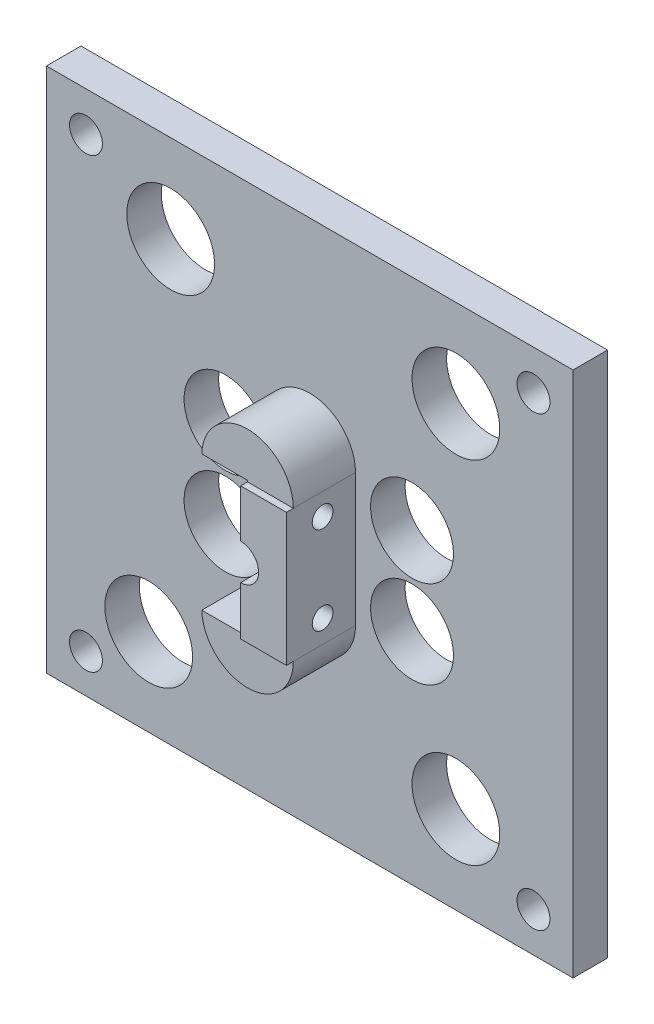
from build123d import *

# Parameters (mm, degrees)
EXTRUDE1_DEPTH = 10
SKETCH7_R      = 1.5
EXTRUDE3_DEPTH = 6.625
SKETCH6_R      = 2.38125
SKETCH6_R_2    = 2.6
SKETCH6_R_3    = 6.35
SKETCH6_R_4    = 6
EXTRUDE2_DEPTH = 5
EXTRUDE4_DEPTH = 9
EXTRUDE5_DEPTH = 9


with BuildPart() as part:
    # Sketch5 → Extrude1 (new body)
    with BuildSketch(Plane.XY):
        with BuildLine():
            Line((-46.55, -2.6), (-46.55, -9.663597854))
            Line((-46.55, -9.663597854), (-39.925, -9.663597854))
            Line((-39.925, -9.663597854), (-39.925, 9.525))
            Line((-39.925, 9.525), (-46.55, 9.525))
            Line((-46.55, 9.525), (-46.55, 2.6))
            ThreePointArc((-46.55, 2.6), (-43.95, 0), (-46.55, -2.6))
        make_face()
    extrude(amount=EXTRUDE1_DEPTH)

    # Sketch7 → Extrude3 (cut)
    with BuildSketch(Plane(origin=(-39.925, 0, 0), x_dir=(0, 0, -1), z_dir=(1, 0, 0))):
        with Locations((-4.7625, 6.35)):
            Circle(SKETCH7_R)
        with Locations((-4.7625, -6.35)):
            Circle(SKETCH7_R)
    extrude(amount=-EXTRUDE3_DEPTH, mode=Mode.SUBTRACT)

    # Sketch6 → Extrude2 (add)
    with BuildSketch(Plane(origin=(0, 0, 0), x_dir=(-1, 0, 0), z_dir=(0, 0, -1))):
        Polygon((84.65, 38.1), (8.45, 38.1), (8.45, -38.1), (84.65, -37.995357572), align=None)
        with Locations((78.93, -32.38)):
            Circle(SKETCH6_R, mode=Mode.SUBTRACT)
        with Locations((14.17, -32.38)):
            Circle(SKETCH6_R, mode=Mode.SUBTRACT)
        with Locations((14.17, 32.38)):
            Circle(SKETCH6_R, mode=Mode.SUBTRACT)
        with Locations((78.93, 32.38)):
            Circle(SKETCH6_R, mode=Mode.SUBTRACT)
        with Locations((46.55, 0)):
            Circle(SKETCH6_R_2, mode=Mode.SUBTRACT)
        with Locations((69.85, -25.4)):
            Circle(SKETCH6_R_3, mode=Mode.SUBTRACT)
        with Locations((66.675, 25.4)):
            Circle(SKETCH6_R_3, mode=Mode.SUBTRACT)
        with Locations((25.4, 25.4)):
            Circle(SKETCH6_R_3, mode=Mode.SUBTRACT)
        with Locations((25.4, -25.4)):
            Circle(SKETCH6_R_3, mode=Mode.SUBTRACT)
        with Locations((58.7375, -6.35)):
            Circle(SKETCH6_R_4, mode=Mode.SUBTRACT)
        with Locations((58.7375, 6.35)):
            Circle(SKETCH6_R_4, mode=Mode.SUBTRACT)
        with Locations((31.75, -6.35)):
            Circle(SKETCH6_R_4, mode=Mode.SUBTRACT)
        with Locations((31.75, 6.35)):
            Circle(SKETCH6_R_4, mode=Mode.SUBTRACT)
    extrude(amount=EXTRUDE2_DEPTH)

    # Sketch9 → Extrude4 (add)
    with BuildSketch(Plane.XY):
        with BuildLine():
            Line((-53.175, -9.663597854), (-39.925, -9.663597854))
            ThreePointArc((-39.925, -9.663597854), (-46.55, -16.288597854), (-53.175, -9.663597854))
        make_face()
        with BuildLine():
            Line((-39.925, 9.525), (-53.175, 9.525))
            ThreePointArc((-53.175, 9.525), (-46.55, 16.15), (-39.925, 9.525))
        make_face()
    extrude(amount=EXTRUDE4_DEPTH)

    # Sketch10 → Extrude5 (cut)
    with BuildSketch(Plane.XY.offset(9)):
        Polygon((-46.55, 9.525), (-46.55, 9.725), (-53.997578108, 9.725), (-53.997578108, -9.863597854), (-46.55, -9.863597854), (-46.55, -9.663597854), align=None)
    extrude(amount=-EXTRUDE5_DEPTH, mode=Mode.SUBTRACT)


solid = part.part
